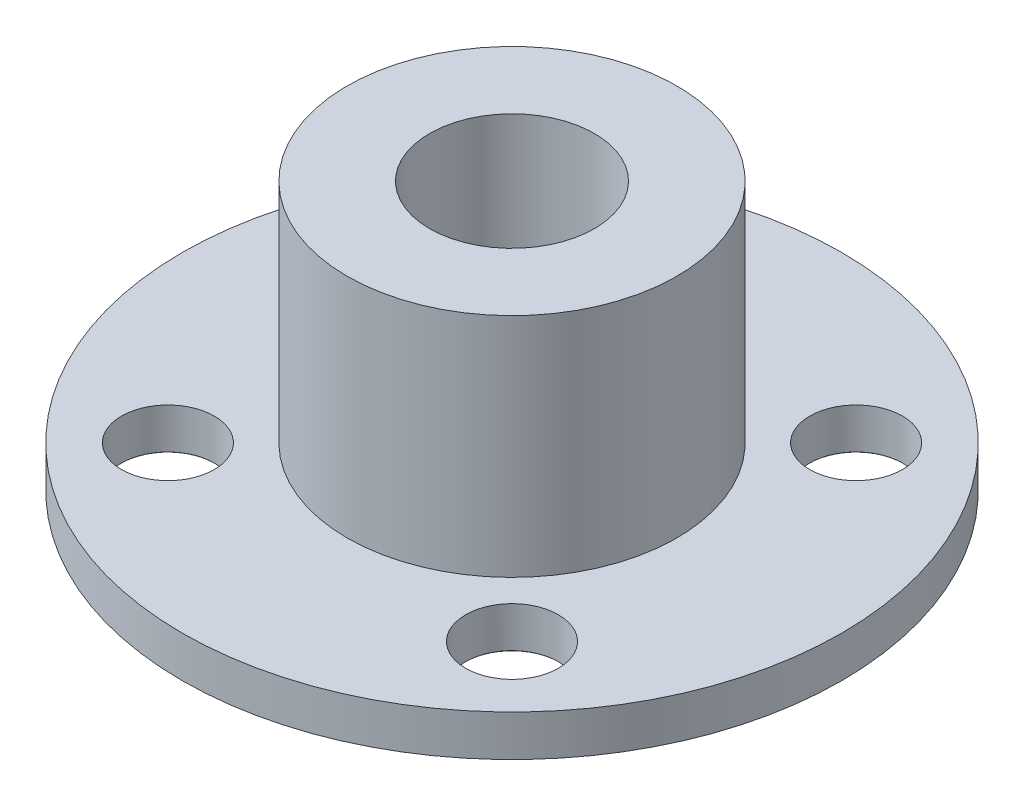
from build123d import *

# Parameters (mm, degrees)
SKETCH1_R                      = 16
SKETCH1_R_2                    = 4
BOSS_EXTRUDE1_DEPTH            = 2
SKETCH2_R                      = 8
SKETCH2_R_2                    = 4
BOSS_EXTRUDE2_DEPTH            = 11
M4_CLEARANCE_HOLE1_D           = 4.5
M4_CLEARANCE_HOLE1_DEPTH       = 13
M4_CLEARANCE_HOLE1_CSINK_D     = 4.55
M4_CLEARANCE_HOLE1_CSINK_ANGLE = 90
M4_CLEARANCE_HOLE1_TIP         = 1.351936393


with BuildPart() as part:
    # Sketch1 → Boss-Extrude1 (new body)
    with BuildSketch(Plane(origin=(0, 0, 0), x_dir=(1, 0, 0), z_dir=(0, 1, 0))):
        Circle(SKETCH1_R)
        Circle(SKETCH1_R_2, mode=Mode.SUBTRACT)
    extrude(amount=BOSS_EXTRUDE1_DEPTH)

    # Sketch2 → Boss-Extrude2 (add)
    with BuildSketch(Plane(origin=(0, 2, 0), x_dir=(1, 0, 0), z_dir=(0, 1, 0))):
        Circle(SKETCH2_R)
        Circle(SKETCH2_R_2, mode=Mode.SUBTRACT)
    extrude(amount=BOSS_EXTRUDE2_DEPTH)

    # M4 Clearance Hole1
    with Locations(Plane(origin=(0, 0, 0), x_dir=(-1, 0, 0), z_dir=(0, -1, 0))):
        with Locations((-8.35, 8.35), (8.35, 8.35), (8.35, -8.35), (-8.35, -8.35)):
            CounterSinkHole(M4_CLEARANCE_HOLE1_D / 2, M4_CLEARANCE_HOLE1_CSINK_D / 2, depth=M4_CLEARANCE_HOLE1_DEPTH, counter_sink_angle=M4_CLEARANCE_HOLE1_CSINK_ANGLE)
            with Locations((0, 0, -(M4_CLEARANCE_HOLE1_DEPTH + M4_CLEARANCE_HOLE1_TIP / 2))):  # 118° drill point
                Cone(0, M4_CLEARANCE_HOLE1_D / 2, M4_CLEARANCE_HOLE1_TIP, mode=Mode.SUBTRACT)


solid = part.part
